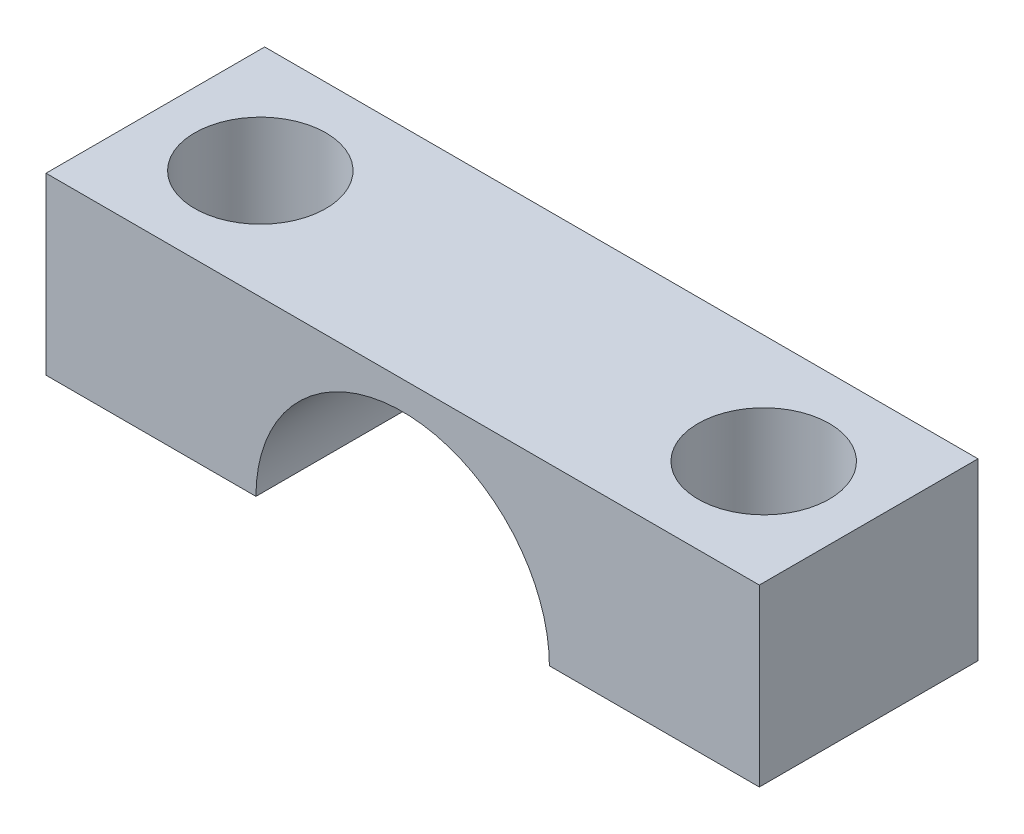
from build123d import *

# Parameters (mm, degrees)
SKETCH1_W                = 16.31
SKETCH1_H                = 4
BOSS_EXTRUDE3_DEPTH      = 5
CUT_EXTRUDE9_DEPTH       = 5
SKETCH4_R                = 1.5
CUT_EXTRUDE10_DEPTH      = 2.5
CUT_EXTRUDE10_DEPTH_BACK = 2.5


with BuildPart() as part:
    # Sketch1 → Boss-Extrude3 (new body)
    with BuildSketch(Plane.XY):
        Rectangle(SKETCH1_W, SKETCH1_H)
    extrude(amount=-BOSS_EXTRUDE3_DEPTH)

    # Sketch3 → Cut-Extrude9 (cut)
    with BuildSketch(Plane.XY):
        with BuildLine():
            Line((-3.355, -2), (3.355, -2))
            ThreePointArc((3.355, -2), (0, 1.355), (-3.355, -2))
        make_face()
    extrude(amount=-CUT_EXTRUDE9_DEPTH, mode=Mode.SUBTRACT)

    # Sketch4 → Cut-Extrude10 (cut, two sides)
    with BuildSketch(Plane(origin=(0, 0, 0), x_dir=(1, 0, 0), z_dir=(0, 1, 0))) as cut_extrude10_sk:
        with Locations((-5.755, 2.5)):
            Circle(SKETCH4_R)
        with Locations((5.755, 2.5)):
            Circle(SKETCH4_R)
    extrude(amount=CUT_EXTRUDE10_DEPTH, mode=Mode.SUBTRACT)
    extrude(cut_extrude10_sk.sketch, amount=-CUT_EXTRUDE10_DEPTH_BACK, mode=Mode.SUBTRACT)


solid = part.part
